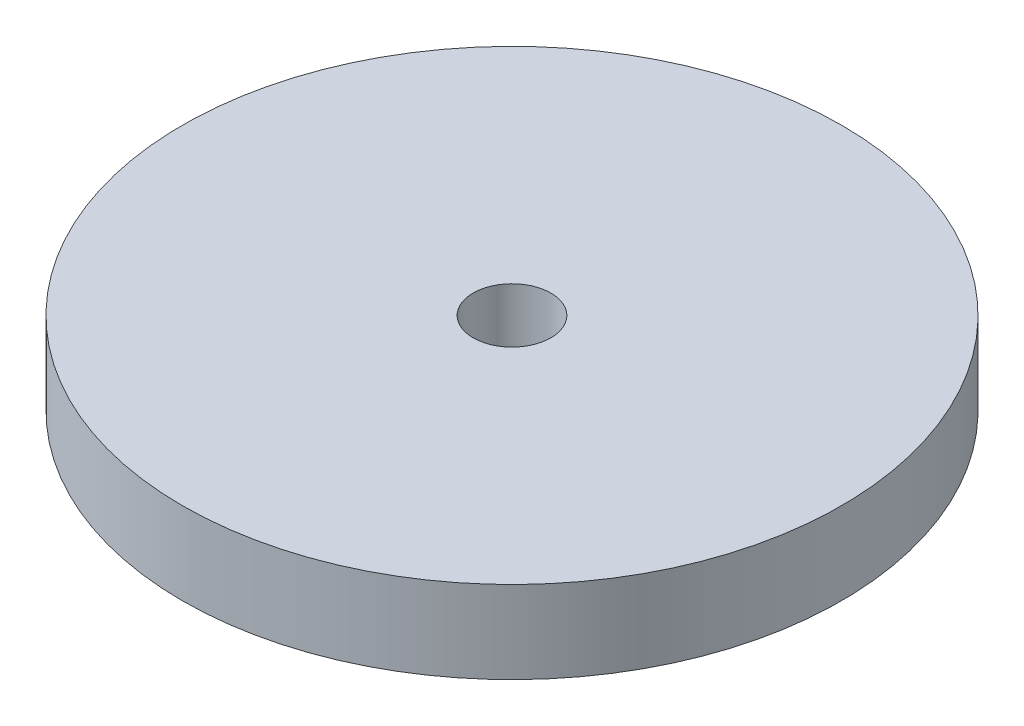
from build123d import *

# Parameters (mm, degrees)
SKETCH1_R           = 14
BOSS_EXTRUDE1_DEPTH = 4
SKETCH2_R           = 14
SKETCH2_R_2         = 6.5
CUT_EXTRUDE1_DEPTH  = 0.5
SKETCH3_R           = 1.65
CUT_EXTRUDE2_DEPTH  = 4


with BuildPart() as part:
    # Sketch1 → Boss-Extrude1 (new body)
    with BuildSketch(Plane(origin=(0, 0, 0), x_dir=(1, 0, 0), z_dir=(0, 1, 0))):
        Circle(SKETCH1_R)
    extrude(amount=BOSS_EXTRUDE1_DEPTH)

    # Sketch2 → Cut-Extrude1 (cut)
    with BuildSketch(Plane.XZ):
        Circle(SKETCH2_R)
        Circle(SKETCH2_R_2, mode=Mode.SUBTRACT)
    extrude(amount=-CUT_EXTRUDE1_DEPTH, mode=Mode.SUBTRACT)

    # Sketch3 → Cut-Extrude2 (cut)
    with BuildSketch(Plane(origin=(0, 4, 0), x_dir=(1, 0, 0), z_dir=(0, 1, 0))):
        Circle(SKETCH3_R)
    extrude(amount=-CUT_EXTRUDE2_DEPTH, mode=Mode.SUBTRACT)


solid = part.part
